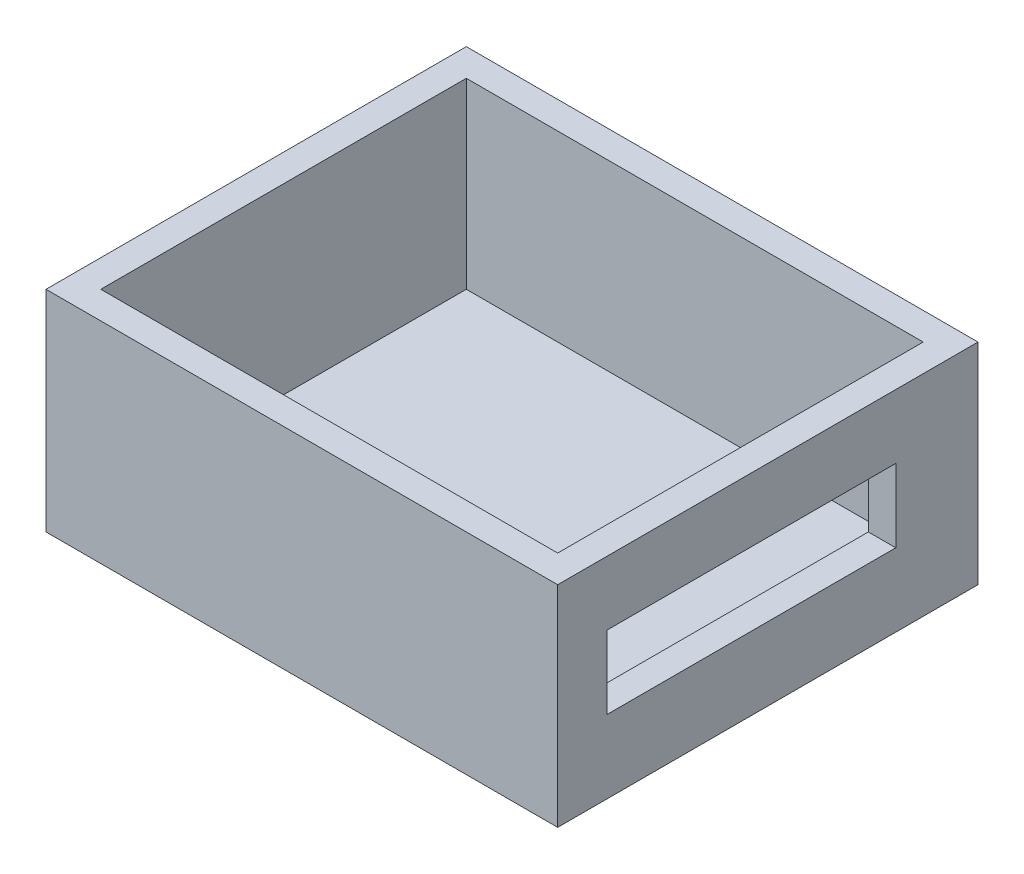
from build123d import *

# Parameters (mm, degrees)
SKETCH1_W           = 25
SKETCH1_H           = 20
BOSS_EXTRUDE1_DEPTH = 1.5
SKETCH2_W           = 28
SKETCH2_H           = 23
SKETCH2_W_2         = 25
SKETCH2_H_2         = 20
BOSS_EXTRUDE2_DEPTH = 11.5
SKETCH3_W           = 15.8
SKETCH3_H           = 4
CUT_EXTRUDE1_DEPTH  = 10


with BuildPart() as part:
    # Sketch1 → Boss-Extrude1 (new body)
    with BuildSketch(Plane(origin=(0, 0, 0), x_dir=(1, 0, 0), z_dir=(0, 1, 0))):
        with Locations((12.5, 10)):
            Rectangle(SKETCH1_W, SKETCH1_H)
    extrude(amount=BOSS_EXTRUDE1_DEPTH)

    # Sketch2 → Boss-Extrude2 (add)
    with BuildSketch(Plane.XZ):
        with Locations((12.5, -10)):
            Rectangle(SKETCH2_W, SKETCH2_H)
        with Locations((12.5, -10)):
            Rectangle(SKETCH2_W_2, SKETCH2_H_2, mode=Mode.SUBTRACT)
    extrude(amount=-BOSS_EXTRUDE2_DEPTH)

    # Sketch3 → Cut-Extrude1 (cut)
    with BuildSketch(Plane.ZY.offset(-25)):
        with Locations((-9.1, 6)):
            Rectangle(SKETCH3_W, SKETCH3_H)
    extrude(amount=-CUT_EXTRUDE1_DEPTH, mode=Mode.SUBTRACT)


solid = part.part
